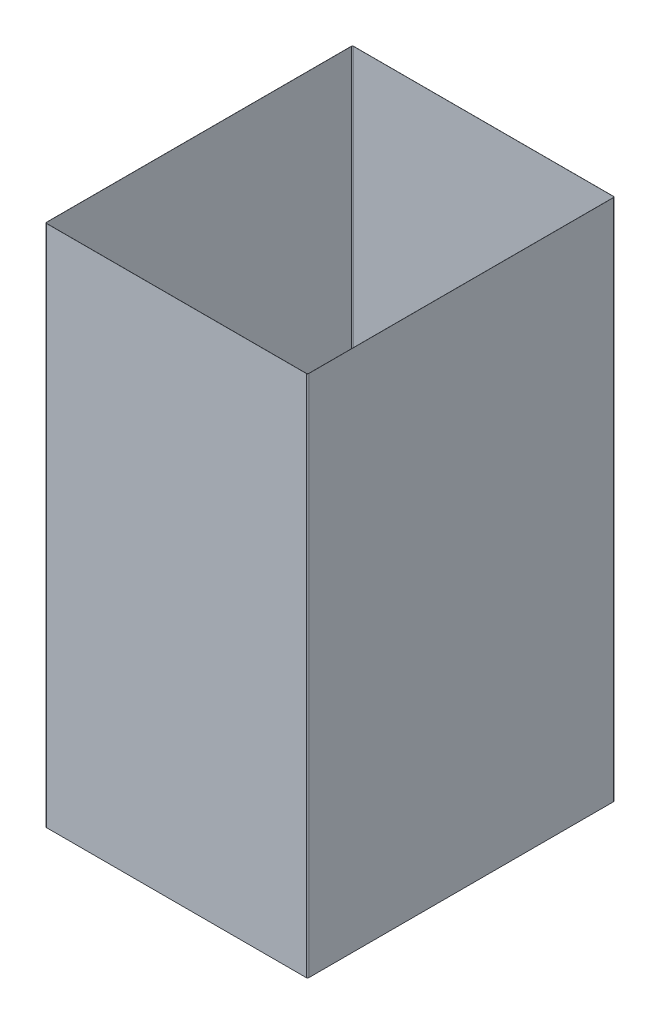
from build123d import *

# Parameters (mm, degrees)
EXTRUDE_THIN1_DEPTH = 484.8


with BuildPart() as part:
    # Sketch1 → Extrude-Thin1 (new body)
    with BuildSketch(Plane(origin=(0, 0, 0), x_dir=(1, 0, 0), z_dir=(0, 1, 0))):
        with BuildLine():
            Line((-0.1, 283.25), (-0.1, 1))
            ThreePointArc((-0.1, 1), (0.222182541, 0.222182541), (1, -0.1))
            Line((1, -0.1), (241.7, -0.1))
            ThreePointArc((241.7, -0.1), (242.477817459, 0.222182541), (242.8, 1))
            Line((242.8, 1), (242.8, 283.25))
            ThreePointArc((242.8, 283.25), (242.477817459, 284.027817459), (241.7, 284.35))
            Line((241.7, 284.35), (1, 284.35))
            ThreePointArc((1, 284.35), (0.222182541, 284.027817459), (-0.1, 283.25))
        make_face()
        with BuildLine():
            Line((0, 283.25), (0, 1))
            ThreePointArc((0, 1), (0.292893219, 0.292893219), (1, 0))
            Line((1, 0), (241.7, 0))
            ThreePointArc((241.7, 0), (242.407106781, 0.292893219), (242.7, 1))
            Line((242.7, 1), (242.7, 283.25))
            ThreePointArc((242.7, 283.25), (242.407106781, 283.957106781), (241.7, 284.25))
            Line((241.7, 284.25), (1, 284.25))
            ThreePointArc((1, 284.25), (0.292893219, 283.957106781), (0, 283.25))
        make_face(mode=Mode.SUBTRACT)
    extrude(amount=EXTRUDE_THIN1_DEPTH)


solid = part.part
